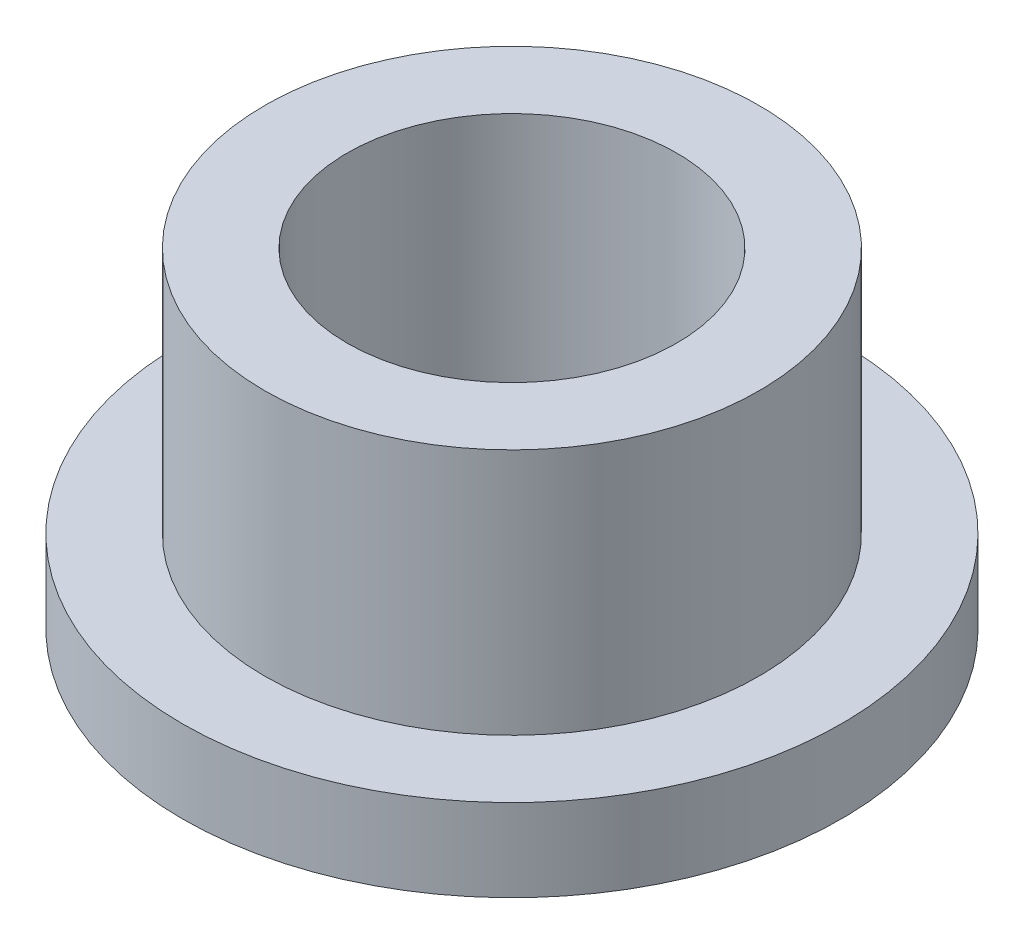
from build123d import *

# Parameters (mm, degrees)
SKETCH2_R           = 4.7625
SKETCH2_R_2         = 3.175
BOSS_EXTRUDE1_DEPTH = 9.525
SKETCH3_R           = 6.35
SKETCH3_R_2         = 4.7625
BOSS_EXTRUDE2_DEPTH = 1.5875
SKETCH4_R           = 6.35
CUT_EXTRUDE1_DEPTH  = 3.175


with BuildPart() as part:
    # Sketch2 → Boss-Extrude1 (new body)
    with BuildSketch(Plane(origin=(0, 0, 0), x_dir=(1, 0, 0), z_dir=(0, 1, 0))):
        Circle(SKETCH2_R)
        Circle(SKETCH2_R_2, mode=Mode.SUBTRACT)
    extrude(amount=BOSS_EXTRUDE1_DEPTH)

    # Sketch3 → Boss-Extrude2 (add)
    with BuildSketch(Plane(origin=(0, 0, 0), x_dir=(1, 0, 0), z_dir=(0, 1, 0))):
        Circle(SKETCH3_R)
        Circle(SKETCH3_R_2, mode=Mode.SUBTRACT)
    extrude(amount=BOSS_EXTRUDE2_DEPTH)

    # Sketch4 → Cut-Extrude1 (cut)
    with BuildSketch(Plane(origin=(0, 9.525, 0), x_dir=(1, 0, 0), z_dir=(0, 1, 0))):
        Circle(SKETCH4_R)
    extrude(amount=-CUT_EXTRUDE1_DEPTH, mode=Mode.SUBTRACT)


solid = part.part
